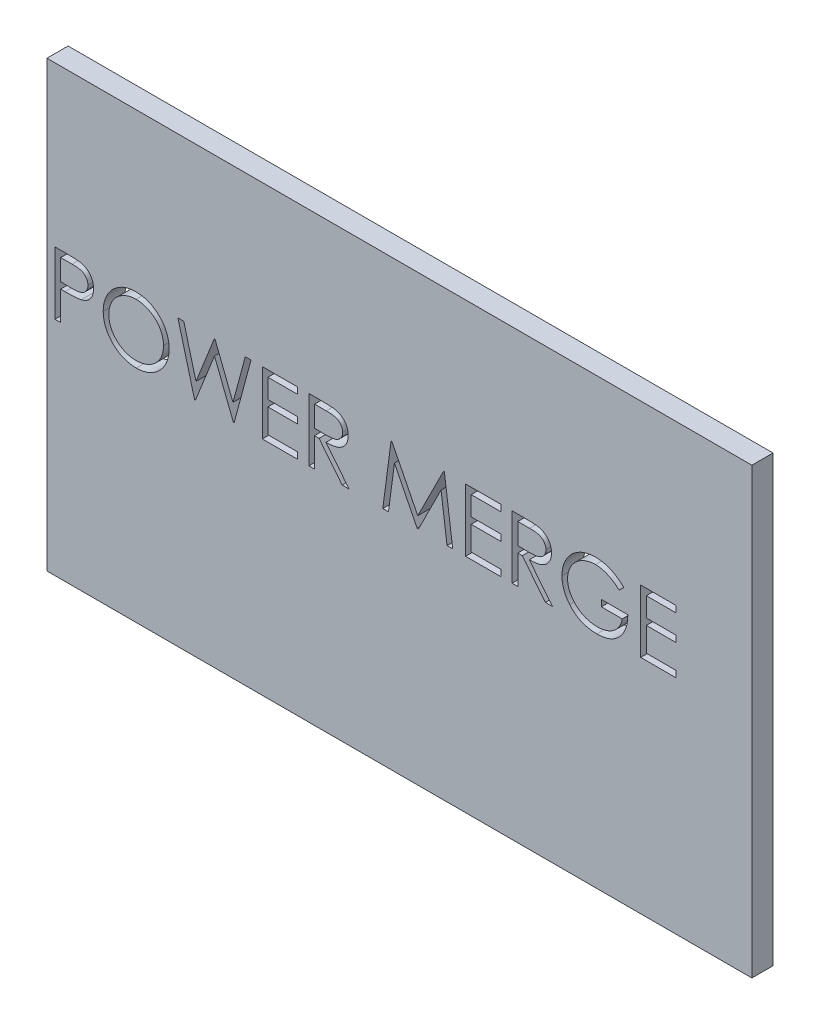
from build123d import *

# Parameters (mm, degrees)
SKETCH1_W               = 100
SKETCH1_H               = 63
BOSS_EXTRUDE1_DEPTH     = 3
CUT_EXTRUDE1_DEPTH      = 1
CUT_EXTRUDE1_DEPTH_BACK = 4


with BuildPart() as part:
    # Sketch1 → Boss-Extrude1 (new body)
    with BuildSketch(Plane.XY):
        Rectangle(SKETCH1_W, SKETCH1_H)
    extrude(amount=BOSS_EXTRUDE1_DEPTH)

    # Sketch2 → Cut-Extrude1 (cut, two sides)
    with BuildSketch(Plane.XY.offset(3)) as cut_extrude1_sk:
        with BuildLine():
            Line((-48.86025641, 8.89), (-47.116804888, 8.89))
            add(Edge.make_bspline(
                [(-47.116804888, 8.89), (-46.996889186, 8.889868184), (-46.767125376, 8.889615617), (-46.437649135, 8.881958163), (-46.138412417, 8.871730365), (-45.870060449, 8.857552356), (-45.63176756, 8.840797017), (-45.424612019, 8.817296837), (-45.246965546, 8.792759686), (-45.140523164, 8.767813314), (-45.091979167, 8.756436298)],
                knots=[0, 0, 0, 0, 0.000359736, 0.00068927, 0.000988644, 0.001257929, 0.00149545, 0.001705092, 0.001883408, 0.002032915, 0.002032915, 0.002032915, 0.002032915], degree=3))
            add(Edge.make_bspline(
                [(-45.091979167, 8.756436298), (-45.030527591, 8.739616546), (-44.909072469, 8.706373377), (-44.734063819, 8.639790519), (-44.567557052, 8.56084182), (-44.408980893, 8.470865012), (-44.260284002, 8.365999679), (-44.119247858, 8.25049669), (-43.987117108, 8.121689306), (-43.864634773, 7.981022227), (-43.752151387, 7.830856894), (-43.655301993, 7.66895163), (-43.574206836, 7.498031719), (-43.504653327, 7.318216048), (-43.454593852, 7.127994627), (-43.416882727, 6.928689177), (-43.392946713, 6.720321064), (-43.390654206, 6.577929001), (-43.389487179, 6.505442708)],
                knots=[0, 0, 0, 0, 0.00019105, 0.000377597, 0.000560817, 0.000743491, 0.000923815, 0.001106002, 0.001289869, 0.001476664, 0.00166508, 0.001851993, 0.002041568, 0.002232077, 0.002429503, 0.002630684, 0.002840325, 0.003057705, 0.003057705, 0.003057705, 0.003057705], degree=3))
            add(Edge.make_bspline(
                [(-43.389487179, 6.505442708), (-43.390557598, 6.432347155), (-43.392651945, 6.289330769), (-43.41778851, 6.080103887), (-43.451647196, 5.880159176), (-43.503709709, 5.689939972), (-43.571897719, 5.510575915), (-43.651887533, 5.339325985), (-43.7483657, 5.179103619), (-43.859223568, 5.02932714), (-43.982544618, 4.889855963), (-44.117807081, 4.761700785), (-44.264464883, 4.645611765), (-44.42205194, 4.541328652), (-44.592104556, 4.451269702), (-44.772043626, 4.370606148), (-44.963433175, 4.302861654), (-45.095875161, 4.267225298), (-45.163213141, 4.249106571)],
                knots=[0, 0, 0, 0, 0.00021916, 0.000428802, 0.000631412, 0.000827119, 0.001019294, 0.001206495, 0.001393408, 0.001579334, 0.001764791, 0.001951228, 0.002137572, 0.002325263, 0.002517281, 0.002714192, 0.002916403, 0.003125552, 0.003125552, 0.003125552, 0.003125552], degree=3))
            add(Edge.make_bspline(
                [(-45.163213141, 4.249106571), (-45.218908569, 4.237262599), (-45.340968339, 4.211305845), (-45.541990853, 4.182328365), (-45.776040133, 4.157594859), (-46.042796724, 4.13904997), (-46.342021183, 4.123174034), (-46.673875377, 4.110555075), (-47.039010733, 4.103621247), (-47.293699693, 4.103263633), (-47.426672676, 4.103076923)],
                knots=[0, 0, 0, 0, 0.000170785, 0.000374286, 0.000608905, 0.00087675, 0.001176362, 0.001507834, 0.001872978, 0.002271892, 0.002271892, 0.002271892, 0.002271892], degree=3))
            Line((-47.426672676, 4.103076923), (-48.062435897, 4.103076923))
            Line((-48.062435897, 4.103076923), (-48.062435897, 0))
            Line((-48.062435897, 0), (-48.86025641, 0))
            Line((-48.86025641, 0), (-48.86025641, 8.89))
        make_face()
        with BuildLine():
            Line((-48.062435897, 7.978205128), (-48.062435897, 5.014871795))
            Line((-48.062435897, 5.014871795), (-46.505973558, 4.995282452))
            add(Edge.make_bspline(
                [(-46.505973558, 4.995282452), (-46.429976946, 4.995243174), (-46.283267054, 4.99516735), (-46.071339047, 5.005289818), (-45.874719458, 5.016975171), (-45.694012236, 5.034084416), (-45.529135923, 5.05826841), (-45.379815599, 5.082682224), (-45.247209101, 5.118001845), (-45.092017128, 5.165558441), (-44.919085426, 5.246667285), (-44.730953852, 5.364396006), (-44.571516563, 5.514461004), (-44.433548089, 5.683187696), (-44.324059159, 5.870891485), (-44.243906939, 6.071726584), (-44.196812399, 6.283633322), (-44.190497467, 6.428637195), (-44.187307692, 6.50188101)],
                knots=[0, 0, 0, 0, 0.000227956, 0.000440064, 0.000636353, 0.000818871, 0.000984337, 0.001136294, 0.001272352, 0.001395694, 0.001622813, 0.001843128, 0.00205864, 0.002276414, 0.002495104, 0.002707742, 0.002922923, 0.003142553, 0.003142553, 0.003142553, 0.003142553], degree=3))
            add(Edge.make_bspline(
                [(-44.187307692, 6.50188101), (-44.190514814, 6.573352834), (-44.196890176, 6.715429974), (-44.244276069, 6.923656026), (-44.323903326, 7.122374716), (-44.434283076, 7.307726352), (-44.568245546, 7.475845914), (-44.723945878, 7.621888617), (-44.901017561, 7.739291742), (-45.065732068, 7.815068277), (-45.212039081, 7.861335077), (-45.339120259, 7.893706972), (-45.482606572, 7.919553012), (-45.642544732, 7.940481349), (-45.81769509, 7.95839714), (-46.00956241, 7.970553522), (-46.217419864, 7.977669221), (-46.361718714, 7.978022168), (-46.436520433, 7.978205128)],
                knots=[0, 0, 0, 0, 0.000214302, 0.000426006, 0.00063699, 0.000854144, 0.001070801, 0.001279973, 0.001491864, 0.001705425, 0.00182144, 0.001951881, 0.002098582, 0.002258512, 0.002435713, 0.002626671, 0.002835152, 0.003059546, 0.003059546, 0.003059546, 0.003059546], degree=3))
            Line((-46.436520433, 7.978205128), (-48.062435897, 7.978205128))
        make_face(mode=Mode.SUBTRACT)
        with BuildLine():
            add(Edge.make_bspline(
                [(-37.405833333, 9.117948718), (-37.241220744, 9.11377936), (-36.917908038, 9.105590398), (-36.442737798, 9.042905475), (-35.989106256, 8.934459184), (-35.553318103, 8.790027209), (-35.140585943, 8.59735707), (-34.747803156, 8.364476793), (-34.375904297, 8.088946588), (-34.029901987, 7.772896352), (-33.713273334, 7.429022379), (-33.434315583, 7.062048487), (-33.200528157, 6.67419353), (-33.008540257, 6.26662302), (-32.857921789, 5.840258701), (-32.753987418, 5.392827534), (-32.687596516, 4.927228541), (-32.679834842, 4.609660305), (-32.675897436, 4.448561699)],
                knots=[0, 0, 0, 0, 0.000493758, 0.000969781, 0.001434566, 0.001891287, 0.002344652, 0.002798196, 0.003259088, 0.003730593, 0.004201984, 0.004659666, 0.005111068, 0.005557979, 0.006009125, 0.006464835, 0.006934037, 0.00741712, 0.00741712, 0.00741712, 0.00741712], degree=3))
            add(Edge.make_bspline(
                [(-32.675897436, 4.448561699), (-32.679834265, 4.288649785), (-32.68759421, 3.973444877), (-32.754062905, 3.510800529), (-32.858307045, 3.06607016), (-33.007141561, 2.639996202), (-33.198214276, 2.23212919), (-33.433558411, 1.843542327), (-33.710777086, 1.474108221), (-34.026262488, 1.127874051), (-34.370181134, 0.810380476), (-34.739066012, 0.533726532), (-35.124621045, 0.295667255), (-35.531807703, 0.105716723), (-35.955225797, -0.046103955), (-36.398664898, -0.149615635), (-36.860047145, -0.216384725), (-37.174679494, -0.224051755), (-37.334599359, -0.227948718)],
                knots=[0, 0, 0, 0, 0.000479525, 0.000945199, 0.001399176, 0.001848053, 0.002296576, 0.002747978, 0.003208506, 0.003680011, 0.004151401, 0.004610505, 0.005061309, 0.005508221, 0.005956008, 0.006408253, 0.006872163, 0.007351688, 0.007351688, 0.007351688, 0.007351688], degree=3))
            add(Edge.make_bspline(
                [(-37.334599359, -0.227948718), (-37.495697129, -0.224013275), (-37.813263718, -0.21625547), (-38.279447788, -0.149754702), (-38.727193257, -0.045763791), (-39.155219709, 0.102850177), (-39.56376583, 0.294917944), (-39.95363064, 0.529117066), (-40.323249274, 0.807011205), (-40.66955731, 1.122394304), (-40.986420274, 1.465730047), (-41.262669088, 1.833609054), (-41.496920876, 2.218813914), (-41.68834374, 2.622413626), (-41.839891467, 3.04245709), (-41.943281705, 3.481746223), (-42.010175023, 3.937776568), (-42.017883533, 4.248273529), (-42.021794872, 4.405821314)],
                knots=[0, 0, 0, 0, 0.000483083, 0.000952285, 0.001409728, 0.001860286, 0.002308809, 0.002761737, 0.003222265, 0.00369377, 0.00416516, 0.00462177, 0.005071649, 0.005515341, 0.005959773, 0.006408554, 0.006867174, 0.007339583, 0.007339583, 0.007339583, 0.007339583], degree=3))
            add(Edge.make_bspline(
                [(-42.021794872, 4.405821314), (-42.020436898, 4.511568294), (-42.017738081, 4.721728207), (-41.985247182, 5.033809372), (-41.938100461, 5.340871643), (-41.870531603, 5.64204185), (-41.782160769, 5.936582752), (-41.677888619, 6.226525689), (-41.550533412, 6.508932347), (-41.406564566, 6.785140562), (-41.245879574, 7.050844643), (-41.06839517, 7.301998784), (-40.880345334, 7.540710516), (-40.674190314, 7.760793906), (-40.456724543, 7.968651393), (-40.224420263, 8.161088694), (-39.978694962, 8.33984107), (-39.718491318, 8.500928736), (-39.450220899, 8.646620938), (-39.173673884, 8.77164444), (-38.892606192, 8.878949436), (-38.605701387, 8.965921132), (-38.313721345, 9.034582503), (-38.016028813, 9.081337182), (-37.71286095, 9.113910949), (-37.5086162, 9.116597004), (-37.405833333, 9.117948718)],
                knots=[0, 0, 0, 0, 0.000317116, 0.000630232, 0.000940289, 0.001248767, 0.00155529, 0.001862325, 0.002172429, 0.002483879, 0.00279632, 0.003103133, 0.003406008, 0.003707183, 0.004006979, 0.004307959, 0.004611456, 0.00491783, 0.005225397, 0.00552665, 0.005827629, 0.006127331, 0.006425393, 0.006726657, 0.007030911, 0.007339127, 0.007339127, 0.007339127, 0.007339127], degree=3))
        make_face()
        with BuildLine():
            add(Edge.make_bspline(
                [(-37.366654647, 8.206153846), (-37.451019817, 8.205125425), (-37.618943618, 8.203078414), (-37.86858634, 8.176114497), (-38.114945852, 8.137684579), (-38.358073032, 8.082867516), (-38.596950607, 8.008181222), (-38.833805204, 7.922225315), (-39.066476961, 7.817523745), (-39.29419776, 7.699229076), (-39.51496205, 7.568294817), (-39.723274312, 7.423586529), (-39.919673828, 7.268497801), (-40.103679725, 7.102666694), (-40.274751702, 6.925248705), (-40.436256844, 6.738933518), (-40.581721582, 6.538395714), (-40.715034947, 6.329073281), (-40.834333261, 6.111238865), (-40.940417262, 5.887185815), (-41.027193844, 5.65508649), (-41.09796428, 5.41745893), (-41.1566378, 5.174679482), (-41.193807967, 4.924906426), (-41.22106816, 4.669394842), (-41.222998167, 4.496720933), (-41.223974359, 4.409383013)],
                knots=[0, 0, 0, 0, 0.000252981, 0.000503543, 0.000752404, 0.001000812, 0.001250366, 0.001502782, 0.001756289, 0.002015156, 0.002272315, 0.002525734, 0.002775491, 0.003022625, 0.003268208, 0.003514488, 0.003761686, 0.00401068, 0.004258551, 0.00450632, 0.00475373, 0.005001063, 0.005249872, 0.005502251, 0.00575813, 0.006020011, 0.006020011, 0.006020011, 0.006020011], degree=3))
            add(Edge.make_bspline(
                [(-41.223974359, 4.409383013), (-41.22073621, 4.280954972), (-41.214365768, 4.028297285), (-41.15859354, 3.6580462), (-41.072685725, 3.302221952), (-40.946048014, 2.962771503), (-40.787677453, 2.636777024), (-40.592029152, 2.327130438), (-40.360231074, 2.033748058), (-40.096925717, 1.758678074), (-39.809086042, 1.507609732), (-39.503440908, 1.287230674), (-39.183264745, 1.100768639), (-38.84772261, 0.948863755), (-38.498605861, 0.828493821), (-38.133664881, 0.745998098), (-37.755330714, 0.691704442), (-37.49744285, 0.686490441), (-37.366654647, 0.683846154)],
                knots=[0, 0, 0, 0, 0.000385075, 0.000757563, 0.001120808, 0.001481402, 0.001842195, 0.002206334, 0.002577917, 0.00296209, 0.003347071, 0.003722192, 0.004090862, 0.00445667, 0.004825546, 0.005196622, 0.005577678, 0.005969792, 0.005969792, 0.005969792, 0.005969792], degree=3))
            add(Edge.make_bspline(
                [(-37.366654647, 0.683846154), (-37.278746513, 0.685053935), (-37.104398281, 0.687449328), (-36.845075654, 0.711575967), (-36.590424876, 0.750264915), (-36.340803125, 0.80596878), (-36.096493705, 0.875684685), (-35.856476905, 0.958508314), (-35.623309247, 1.061838571), (-35.394049259, 1.176006368), (-35.174602805, 1.306156368), (-34.965114953, 1.445953268), (-34.770865964, 1.600813565), (-34.586997723, 1.764180809), (-34.415223393, 1.939348982), (-34.256704573, 2.126090346), (-34.111975037, 2.325583615), (-33.978712295, 2.534588546), (-33.859832008, 2.753019028), (-33.756253096, 2.97788441), (-33.668378962, 3.208630987), (-33.59744056, 3.445591579), (-33.541851487, 3.688316135), (-33.50354849, 3.937129653), (-33.476755456, 4.191534383), (-33.47473596, 4.363603777), (-33.473717949, 4.450342548)],
                knots=[0, 0, 0, 0, 0.000263662, 0.000522921, 0.000780578, 0.001035936, 0.001289606, 0.001542493, 0.001796911, 0.002054156, 0.002310407, 0.002561816, 0.002809072, 0.003055016, 0.003299324, 0.003544448, 0.003789157, 0.004038152, 0.004287585, 0.004534604, 0.004780348, 0.005027681, 0.005276089, 0.005526708, 0.005782587, 0.006042689, 0.006042689, 0.006042689, 0.006042689], degree=3))
            add(Edge.make_bspline(
                [(-33.473717949, 4.450342548), (-33.474736776, 4.536487929), (-33.476757807, 4.70737316), (-33.503535692, 4.960003639), (-33.541891954, 5.207026796), (-33.597169232, 5.447472856), (-33.668416623, 5.681403109), (-33.756268442, 5.908597849), (-33.859863102, 6.129903464), (-33.978755992, 6.344772978), (-34.112400184, 6.550956813), (-34.258435562, 6.748066941), (-34.419383546, 6.932401704), (-34.59064565, 7.108511827), (-34.776499698, 7.272641266), (-34.976103805, 7.424844469), (-35.187034747, 7.568794585), (-35.410369925, 7.698653512), (-35.640859567, 7.818577664), (-35.87736902, 7.921323211), (-36.117218933, 8.008628395), (-36.359799379, 8.083093486), (-36.607152144, 8.137469883), (-36.857605869, 8.176149129), (-37.110814046, 8.203069029), (-37.281103824, 8.205122311), (-37.366654647, 8.206153846)],
                knots=[0, 0, 0, 0, 0.000258321, 0.000512428, 0.000761289, 0.00100796, 0.001251885, 0.001494303, 0.001738091, 0.001984402, 0.002230398, 0.002474731, 0.002719661, 0.002963969, 0.003211244, 0.003462716, 0.003716598, 0.003976822, 0.004237271, 0.004495666, 0.004749754, 0.005002716, 0.005256335, 0.005508714, 0.00576282, 0.006019361, 0.006019361, 0.006019361, 0.006019361], degree=3))
        make_face(mode=Mode.SUBTRACT)
        Polygon((-31.422179487, 8.89), (-30.597646234, 8.89), (-28.85775641, 2.370310497), (-26.270182292, 8.89), (-26.154427083, 8.89), (-23.614935897, 2.414831731), (-21.866141827, 8.89), (-21.050512821, 8.89), (-23.447536058, 0), (-23.561510417, 0), (-26.236346154, 6.799282853), (-28.943237179, 0), (-29.057211538, 0), align=None)
        Polygon((-19.454871795, 8.89), (-14.44, 8.89), (-14.44, 7.978205128), (-18.657051282, 7.978205128), (-18.657051282, 5.242820513), (-14.44, 5.242820513), (-14.44, 4.331025641), (-18.657051282, 4.331025641), (-18.657051282, 0.911794872), (-14.44, 0.911794872), (-14.44, 0), (-19.454871795, 0), align=None)
        with BuildLine():
            Line((-12.844358974, 8.89), (-11.065290465, 8.89))
            add(Edge.make_bspline(
                [(-11.065290465, 8.89), (-10.946567998, 8.889604812), (-10.718607712, 8.888846006), (-10.392031605, 8.884614968), (-10.095290778, 8.872488105), (-9.828540387, 8.862052303), (-9.591785323, 8.843022772), (-9.384299604, 8.824834728), (-9.207038853, 8.80102563), (-9.09973439, 8.778913855), (-9.05114984, 8.768902244)],
                knots=[0, 0, 0, 0, 0.000356174, 0.000683894, 0.000979708, 0.001247126, 0.001484648, 0.001692153, 0.001871975, 0.002020758, 0.002020758, 0.002020758, 0.002020758], degree=3))
            add(Edge.make_bspline(
                [(-9.05114984, 8.768902244), (-8.986109014, 8.75283226), (-8.857414861, 8.721035108), (-8.672121693, 8.653827722), (-8.495555311, 8.576053875), (-8.328449157, 8.484706026), (-8.171640247, 8.379106085), (-8.023511738, 8.261077054), (-7.883391461, 8.131264752), (-7.75694612, 7.986396254), (-7.637720929, 7.83441152), (-7.537165818, 7.670063977), (-7.450484559, 7.498203697), (-7.381471446, 7.317082856), (-7.325901393, 7.128457956), (-7.286718745, 6.930620412), (-7.263220729, 6.724471535), (-7.260828416, 6.583862447), (-7.259615385, 6.512566106)],
                knots=[0, 0, 0, 0, 0.000200865, 0.000397446, 0.000590378, 0.000779266, 0.000967943, 0.001156789, 0.00134704, 0.001540038, 0.001733094, 0.00192583, 0.002116971, 0.00230978, 0.002506457, 0.00270623, 0.002914102, 0.003127922, 0.003127922, 0.003127922, 0.003127922], degree=3))
            add(Edge.make_bspline(
                [(-7.259615385, 6.512566106), (-7.26334664, 6.39411294), (-7.270627285, 6.162980134), (-7.338509048, 5.827545495), (-7.449701409, 5.514644636), (-7.602922563, 5.224671535), (-7.798044031, 4.963278496), (-8.032549, 4.73368674), (-8.306568294, 4.541561362), (-8.561658756, 4.408331238), (-8.786992823, 4.32300525), (-8.972497438, 4.262968898), (-9.174851561, 4.216583507), (-9.39211639, 4.175028772), (-9.625196075, 4.143655468), (-9.873531975, 4.120677118), (-10.137301201, 4.106315834), (-10.318502437, 4.104177142), (-10.41171875, 4.103076923)],
                knots=[0, 0, 0, 0, 0.000355033, 0.000692761, 0.001021712, 0.001348342, 0.001672813, 0.001996463, 0.002328523, 0.002673406, 0.002856626, 0.003050934, 0.003257835, 0.003478926, 0.003714409, 0.003963027, 0.004226978, 0.004506622, 0.004506622, 0.004506622, 0.004506622], degree=3))
            Line((-10.41171875, 4.103076923), (-7.145641026, 0))
            Line((-7.145641026, 0), (-8.132231571, 0))
            Line((-8.132231571, 0), (-11.398309295, 4.103076923))
            Line((-11.398309295, 4.103076923), (-12.046538462, 4.103076923))
            Line((-12.046538462, 4.103076923), (-12.046538462, 0))
            Line((-12.046538462, 0), (-12.844358974, 0))
            Line((-12.844358974, 0), (-12.844358974, 8.89))
        make_face()
        with BuildLine():
            Line((-12.046538462, 7.978205128), (-12.046538462, 5.014871795))
            Line((-12.046538462, 5.014871795), (-10.418842147, 5.002405849))
            add(Edge.make_bspline(
                [(-10.418842147, 5.002405849), (-10.342845249, 5.002372228), (-10.195541613, 5.002307061), (-9.982433925, 5.012451253), (-9.784008841, 5.023991281), (-9.601025331, 5.041642619), (-9.433401649, 5.064391041), (-9.28122158, 5.092846621), (-9.144236708, 5.12599886), (-8.98447442, 5.177310989), (-8.806073631, 5.258606276), (-8.612191723, 5.376882643), (-8.447085785, 5.525648205), (-8.307594414, 5.695760784), (-8.195505659, 5.882796856), (-8.116481041, 6.084514433), (-8.066335237, 6.295821092), (-8.060420732, 6.441053486), (-8.057435897, 6.514346955)],
                knots=[0, 0, 0, 0, 0.000227956, 0.000441843, 0.00063991, 0.0008242, 0.000993193, 0.001147224, 0.001288462, 0.00141574, 0.001650082, 0.001874907, 0.002094378, 0.002313278, 0.002532872, 0.00274551, 0.002961081, 0.003180711, 0.003180711, 0.003180711, 0.003180711], degree=3))
            add(Edge.make_bspline(
                [(-8.057435897, 6.514346955), (-8.060489285, 6.585839252), (-8.066539985, 6.727510899), (-8.115939857, 6.934916911), (-8.199478886, 7.130666964), (-8.31205737, 7.313964756), (-8.449215224, 7.480349325), (-8.610042468, 7.622709094), (-8.790141664, 7.740182734), (-8.958470507, 7.815250861), (-9.108925407, 7.861275288), (-9.239556744, 7.893663244), (-9.387159897, 7.919684195), (-9.552451562, 7.94053267), (-9.734726104, 7.958452228), (-9.934905158, 7.970521746), (-10.15166058, 7.977668961), (-10.301893785, 7.978022246), (-10.379663462, 7.978205128)],
                knots=[0, 0, 0, 0, 0.000214302, 0.000424669, 0.000635359, 0.000850378, 0.001067904, 0.001279832, 0.001492232, 0.00171066, 0.00183007, 0.001963966, 0.002114171, 0.002279397, 0.002463687, 0.002663531, 0.002880911, 0.003114209, 0.003114209, 0.003114209, 0.003114209], degree=3))
            Line((-10.379663462, 7.978205128), (-12.046538462, 7.978205128))
        make_face(mode=Mode.SUBTRACT)
        Polygon((-2.358717949, 0), (-1.185138221, 8.89), (-1.071163862, 8.89), (2.599166667, 1.595641026), (6.260592949, 8.89), (6.376348157, 8.89), (7.557051282, 0), (6.755669071, 0), (5.904423077, 6.396810897), (2.695332532, 0), (2.515466747, 0), (-0.706089744, 6.411057692), (-1.555554888, 0), align=None)
        Polygon((9.380641026, 8.89), (14.395512821, 8.89), (14.395512821, 7.978205128), (10.178461538, 7.978205128), (10.178461538, 5.242820513), (14.395512821, 5.242820513), (14.395512821, 4.331025641), (10.178461538, 4.331025641), (10.178461538, 0.911794872), (14.395512821, 0.911794872), (14.395512821, 0), (9.380641026, 0), align=None)
        with BuildLine():
            Line((15.991153846, 8.89), (17.770222356, 8.89))
            add(Edge.make_bspline(
                [(17.770222356, 8.89), (17.888944822, 8.889604812), (18.116905109, 8.888846006), (18.443481216, 8.884614968), (18.740222042, 8.872488105), (19.006972434, 8.862052303), (19.243727498, 8.843022772), (19.451213216, 8.824834728), (19.628473968, 8.80102563), (19.73577843, 8.778913855), (19.784362981, 8.768902244)],
                knots=[0, 0, 0, 0, 0.000356174, 0.000683894, 0.000979708, 0.001247126, 0.001484648, 0.001692153, 0.001871975, 0.002020758, 0.002020758, 0.002020758, 0.002020758], degree=3))
            add(Edge.make_bspline(
                [(19.784362981, 8.768902244), (19.849403806, 8.75283226), (19.978097959, 8.721035108), (20.163391127, 8.653827722), (20.33995751, 8.576053875), (20.507063664, 8.484706026), (20.663872573, 8.379106085), (20.812001083, 8.261077054), (20.95212136, 8.131264752), (21.0785667, 7.986396254), (21.197791892, 7.83441152), (21.298347003, 7.670063977), (21.385028261, 7.498203697), (21.454041375, 7.317082856), (21.509611427, 7.128457956), (21.548794075, 6.930620412), (21.572292092, 6.724471535), (21.574684405, 6.583862447), (21.575897436, 6.512566106)],
                knots=[0, 0, 0, 0, 0.000200865, 0.000397446, 0.000590378, 0.000779266, 0.000967943, 0.001156789, 0.00134704, 0.001540038, 0.001733094, 0.00192583, 0.002116971, 0.00230978, 0.002506457, 0.00270623, 0.002914102, 0.003127922, 0.003127922, 0.003127922, 0.003127922], degree=3))
            add(Edge.make_bspline(
                [(21.575897436, 6.512566106), (21.572166181, 6.39411294), (21.564885535, 6.162980134), (21.497003772, 5.827545495), (21.385811412, 5.514644636), (21.232590258, 5.224671535), (21.03746879, 4.963278496), (20.80296382, 4.73368674), (20.528944527, 4.541561362), (20.273854064, 4.408331238), (20.048519997, 4.32300525), (19.863015383, 4.262968898), (19.66066126, 4.216583507), (19.44339643, 4.175028772), (19.210316745, 4.143655468), (18.961980845, 4.120677118), (18.69821162, 4.106315834), (18.517010384, 4.104177142), (18.423794071, 4.103076923)],
                knots=[0, 0, 0, 0, 0.000355033, 0.000692761, 0.001021712, 0.001348342, 0.001672813, 0.001996463, 0.002328523, 0.002673406, 0.002856626, 0.003050934, 0.003257835, 0.003478926, 0.003714409, 0.003963027, 0.004226978, 0.004506622, 0.004506622, 0.004506622, 0.004506622], degree=3))
            Line((18.423794071, 4.103076923), (21.689871795, 0))
            Line((21.689871795, 0), (20.70328125, 0))
            Line((20.70328125, 0), (17.437203526, 4.103076923))
            Line((17.437203526, 4.103076923), (16.788974359, 4.103076923))
            Line((16.788974359, 4.103076923), (16.788974359, 0))
            Line((16.788974359, 0), (15.991153846, 0))
            Line((15.991153846, 0), (15.991153846, 8.89))
        make_face()
        with BuildLine():
            Line((16.788974359, 7.978205128), (16.788974359, 5.014871795))
            Line((16.788974359, 5.014871795), (18.416670673, 5.002405849))
            add(Edge.make_bspline(
                [(18.416670673, 5.002405849), (18.492667572, 5.002372228), (18.639971207, 5.002307061), (18.853078896, 5.012451253), (19.051503979, 5.023991281), (19.23448749, 5.041642619), (19.402111171, 5.064391041), (19.554291241, 5.092846621), (19.691276113, 5.12599886), (19.8510384, 5.177310989), (20.02943919, 5.258606276), (20.223321098, 5.376882643), (20.388427036, 5.525648205), (20.527918406, 5.695760784), (20.640007162, 5.882796856), (20.71903178, 6.084514433), (20.769177583, 6.295821092), (20.775092089, 6.441053486), (20.778076923, 6.514346955)],
                knots=[0, 0, 0, 0, 0.000227956, 0.000441843, 0.00063991, 0.0008242, 0.000993193, 0.001147224, 0.001288462, 0.00141574, 0.001650082, 0.001874907, 0.002094378, 0.002313278, 0.002532872, 0.00274551, 0.002961081, 0.003180711, 0.003180711, 0.003180711, 0.003180711], degree=3))
            add(Edge.make_bspline(
                [(20.778076923, 6.514346955), (20.775023536, 6.585839252), (20.768972836, 6.727510899), (20.719572963, 6.934916911), (20.636033935, 7.130666964), (20.52345545, 7.313964756), (20.386297597, 7.480349325), (20.225470353, 7.622709094), (20.045371157, 7.740182734), (19.877042313, 7.815250861), (19.726587413, 7.861275288), (19.595956077, 7.893663244), (19.448352923, 7.919684195), (19.283061259, 7.94053267), (19.100786716, 7.958452228), (18.900607663, 7.970521746), (18.683852241, 7.977668961), (18.533619036, 7.978022246), (18.455849359, 7.978205128)],
                knots=[0, 0, 0, 0, 0.000214302, 0.000424669, 0.000635359, 0.000850378, 0.001067904, 0.001279832, 0.001492232, 0.00171066, 0.00183007, 0.001963966, 0.002114171, 0.002279397, 0.002463687, 0.002663531, 0.002880911, 0.003114209, 0.003114209, 0.003114209, 0.003114209], degree=3))
            Line((18.455849359, 7.978205128), (16.788974359, 7.978205128))
        make_face(mode=Mode.SUBTRACT)
        with BuildLine():
            Line((31.833589744, 7.372716346), (31.14974359, 6.724487179))
            add(Edge.make_bspline(
                [(31.14974359, 6.724487179), (31.025997614, 6.840897572), (30.781456456, 7.070942483), (30.382777439, 7.369420411), (29.966817809, 7.625112305), (29.535748067, 7.833154146), (29.10024334, 7.999150158), (28.666084248, 8.117331634), (28.237724167, 8.192699879), (27.952819432, 8.201712737), (27.812431891, 8.206153846)],
                knots=[0, 0, 0, 0, 0.00050936, 0.001006575, 0.001490979, 0.001972049, 0.002440399, 0.002887104, 0.003320404, 0.003741321, 0.003741321, 0.003741321, 0.003741321], degree=3))
            add(Edge.make_bspline(
                [(27.812431891, 8.206153846), (27.726288553, 8.205103287), (27.554225294, 8.203004894), (27.298645556, 8.176222587), (27.045746298, 8.137703833), (26.796004926, 8.081971463), (26.548935859, 8.011336452), (26.305398393, 7.922981375), (26.064938232, 7.819971055), (25.829820386, 7.700940372), (25.601879507, 7.570181562), (25.386597144, 7.425278269), (25.182601111, 7.270874742), (24.993725631, 7.103105254), (24.818884257, 6.923489497), (24.653915392, 6.735368699), (24.50462106, 6.533603244), (24.369769501, 6.321905354), (24.249470991, 6.103993193), (24.143277011, 5.881964199), (24.054130407, 5.656554809), (23.98359599, 5.427482172), (23.925402929, 5.196518473), (23.884464207, 4.962064483), (23.861383933, 4.723869163), (23.857391612, 4.564364126), (23.855384615, 4.484178686)],
                knots=[0, 0, 0, 0, 0.000258321, 0.000515973, 0.000770111, 0.001025469, 0.001283052, 0.001540488, 0.001802152, 0.002067361, 0.002330662, 0.00258997, 0.002845352, 0.003097655, 0.003347, 0.003596954, 0.0038477, 0.004099153, 0.004349443, 0.004593991, 0.004837055, 0.005075875, 0.005312567, 0.005551181, 0.005789163, 0.006029743, 0.006029743, 0.006029743, 0.006029743], degree=3))
            add(Edge.make_bspline(
                [(23.855384615, 4.484178686), (23.85730414, 4.40221081), (23.861137947, 4.238498886), (23.885675159, 3.994165941), (23.931212889, 3.753461819), (23.99209087, 3.515595561), (24.068242142, 3.280159791), (24.163168714, 3.048175216), (24.275603339, 2.819650423), (24.405744181, 2.596644476), (24.548457138, 2.379415997), (24.708332564, 2.174794811), (24.878158446, 1.980056117), (25.064121751, 1.799523677), (25.260259388, 1.62836858), (25.472431369, 1.471306355), (25.696465619, 1.325311667), (25.932703937, 1.192224508), (26.178583005, 1.073330828), (26.430695157, 0.967606131), (26.689845809, 0.880536615), (26.954673041, 0.809573831), (27.224861151, 0.751407076), (27.50178161, 0.713986576), (27.783398289, 0.686831865), (27.973234415, 0.684846423), (28.068874199, 0.683846154)],
                knots=[0, 0, 0, 0, 0.000245918, 0.000491165, 0.000735668, 0.000980137, 0.001227368, 0.001477379, 0.001731442, 0.001990768, 0.002251558, 0.002510523, 0.002769188, 0.003026087, 0.003287436, 0.003549578, 0.003817298, 0.004089215, 0.004362405, 0.004636245, 0.004908814, 0.005181836, 0.005458459, 0.005737257, 0.006019734, 0.006306539, 0.006306539, 0.006306539, 0.006306539], degree=3))
            add(Edge.make_bspline(
                [(28.068874199, 0.683846154), (28.184135201, 0.686255538), (28.410468904, 0.690986754), (28.743174469, 0.727817489), (29.062714268, 0.785340345), (29.368190425, 0.869581723), (29.659957737, 0.977033057), (29.939085808, 1.106561339), (30.203377021, 1.263134709), (30.453625882, 1.439852331), (30.684149133, 1.636740006), (30.892058608, 1.849196922), (31.074038151, 2.076191811), (31.232800087, 2.316387712), (31.364140069, 2.571772787), (31.471944769, 2.841095496), (31.554579329, 3.124476976), (31.588500965, 3.32028972), (31.605641026, 3.419230769)],
                knots=[0, 0, 0, 0, 0.00034571, 0.000678857, 0.001003001, 0.001318819, 0.001628139, 0.001934864, 0.002240595, 0.002548435, 0.002852856, 0.003148804, 0.003438886, 0.003724378, 0.004011116, 0.004298822, 0.004593588, 0.004894652, 0.004894652, 0.004894652, 0.004894652], degree=3))
            Line((31.605641026, 3.419230769), (28.642307692, 3.419230769))
            Line((28.642307692, 3.419230769), (28.642307692, 4.331025641))
            Line((28.642307692, 4.331025641), (32.403461538, 4.331025641))
            add(Edge.make_bspline(
                [(32.403461538, 4.331025641), (32.399128684, 4.161080619), (32.390648504, 3.828467513), (32.331164458, 3.343403025), (32.235110517, 2.885258924), (32.103893325, 2.453552722), (31.934030113, 2.048896197), (31.727343891, 1.670878497), (31.480526703, 1.321941727), (31.202370182, 0.999237258), (30.890204289, 0.711381059), (30.552463994, 0.458381977), (30.188591295, 0.245269334), (29.798930384, 0.071887251), (29.384756883, -0.063428696), (28.945112398, -0.1593685), (28.480593132, -0.216848607), (28.162237973, -0.224192711), (27.999421074, -0.227948718)],
                knots=[0, 0, 0, 0, 0.000509771, 0.000997714, 0.001463644, 0.001912605, 0.002349189, 0.002777989, 0.003202392, 0.003629091, 0.004053774, 0.004473699, 0.004892748, 0.005316044, 0.005750804, 0.006197585, 0.006664099, 0.007152445, 0.007152445, 0.007152445, 0.007152445], degree=3))
            add(Edge.make_bspline(
                [(27.999421074, -0.227948718), (27.89906533, -0.22650315), (27.701131459, -0.223652024), (27.408800502, -0.203389562), (27.124529745, -0.172196898), (26.848360603, -0.125092284), (26.579277214, -0.067397063), (26.318623468, 0.006483203), (26.065406443, 0.092001699), (25.81923476, 0.18927271), (25.582342811, 0.301976718), (25.353675458, 0.427223202), (25.131968698, 0.564366338), (24.918732739, 0.715777887), (24.712856541, 0.880325335), (24.515667594, 1.05833849), (24.326061984, 1.249273134), (24.207290406, 1.384855818), (24.14744391, 1.453173077)],
                knots=[0, 0, 0, 0, 0.000301048, 0.000593763, 0.000878727, 0.001158615, 0.00143387, 0.001703932, 0.001970869, 0.002235426, 0.002497507, 0.002757316, 0.003017253, 0.003279135, 0.003541404, 0.003807466, 0.00407569, 0.004348107, 0.004348107, 0.004348107, 0.004348107], degree=3))
            add(Edge.make_bspline(
                [(24.14744391, 1.453173077), (24.060611643, 1.561556536), (23.888388435, 1.776524399), (23.666701917, 2.120948258), (23.477722354, 2.477568983), (23.324388086, 2.847379339), (23.204657347, 3.230033419), (23.118789465, 3.625042259), (23.06847895, 4.032914521), (23.061230965, 4.308924293), (23.057564103, 4.448561699)],
                knots=[0, 0, 0, 0, 0.000416407, 0.000825901, 0.001226596, 0.001625781, 0.002025124, 0.002427868, 0.002836952, 0.00325583, 0.00325583, 0.00325583, 0.00325583], degree=3))
            add(Edge.make_bspline(
                [(23.057564103, 4.448561699), (23.058915987, 4.553123981), (23.061602576, 4.760919621), (23.094179387, 5.069421182), (23.140918988, 5.372444941), (23.209618507, 5.669743193), (23.296223019, 5.961514497), (23.404308874, 6.247894325), (23.53015291, 6.529051679), (23.67642007, 6.803051303), (23.839194597, 7.066257312), (24.015852157, 7.317610132), (24.208901301, 7.552532357), (24.415189432, 7.773999144), (24.637177787, 7.979228215), (24.872786723, 8.170119656), (25.122197814, 8.346929528), (25.386195711, 8.506872909), (25.66084003, 8.650544505), (25.945472433, 8.776501102), (26.240006035, 8.880598724), (26.542234228, 8.968924124), (26.85444468, 9.034240581), (27.174371744, 9.081608394), (27.503683028, 9.114020317), (27.726278543, 9.116627007), (27.839144631, 9.117948718)],
                knots=[0, 0, 0, 0, 0.000313556, 0.000623127, 0.000929666, 0.001232933, 0.00153775, 0.001842062, 0.00215054, 0.002461246, 0.002773098, 0.003078455, 0.003382182, 0.00368457, 0.003985745, 0.004288348, 0.004593705, 0.004902178, 0.005213628, 0.005523009, 0.005835069, 0.006150139, 0.006466935, 0.006791074, 0.007120146, 0.007458624, 0.007458624, 0.007458624, 0.007458624], degree=3))
            add(Edge.make_bspline(
                [(27.839144631, 9.117948718), (27.93118977, 9.116476809), (28.113704464, 9.113558186), (28.385295824, 9.09332798), (28.652689282, 9.061263322), (28.916281312, 9.017507284), (29.175174282, 8.95790951), (29.430105714, 8.886590667), (29.681445156, 8.803553438), (29.928404909, 8.704521768), (30.172645508, 8.592117561), (30.415524982, 8.465591468), (30.656213467, 8.322779956), (30.89512836, 8.163258976), (31.133776239, 7.989768295), (31.368382431, 7.797345963), (31.604609909, 7.593580163), (31.756506517, 7.447067416), (31.833589744, 7.372716346)],
                knots=[0, 0, 0, 0, 0.000276124, 0.000547521, 0.000816564, 0.001083864, 0.00134869, 0.001613127, 0.001877809, 0.002142366, 0.002410902, 0.002684116, 0.002963573, 0.003250046, 0.003545689, 0.003848292, 0.004160063, 0.004481292, 0.004481292, 0.004481292, 0.004481292], degree=3))
        make_face()
        Polygon((34.227051282, 8.89), (39.241923077, 8.89), (39.241923077, 7.978205128), (35.024871795, 7.978205128), (35.024871795, 5.242820513), (39.241923077, 5.242820513), (39.241923077, 4.331025641), (35.024871795, 4.331025641), (35.024871795, 0.911794872), (39.241923077, 0.911794872), (39.241923077, 0), (34.227051282, 0), align=None)
    extrude(amount=CUT_EXTRUDE1_DEPTH, mode=Mode.SUBTRACT)
    extrude(cut_extrude1_sk.sketch, amount=-CUT_EXTRUDE1_DEPTH_BACK, mode=Mode.SUBTRACT)


solid = part.part
